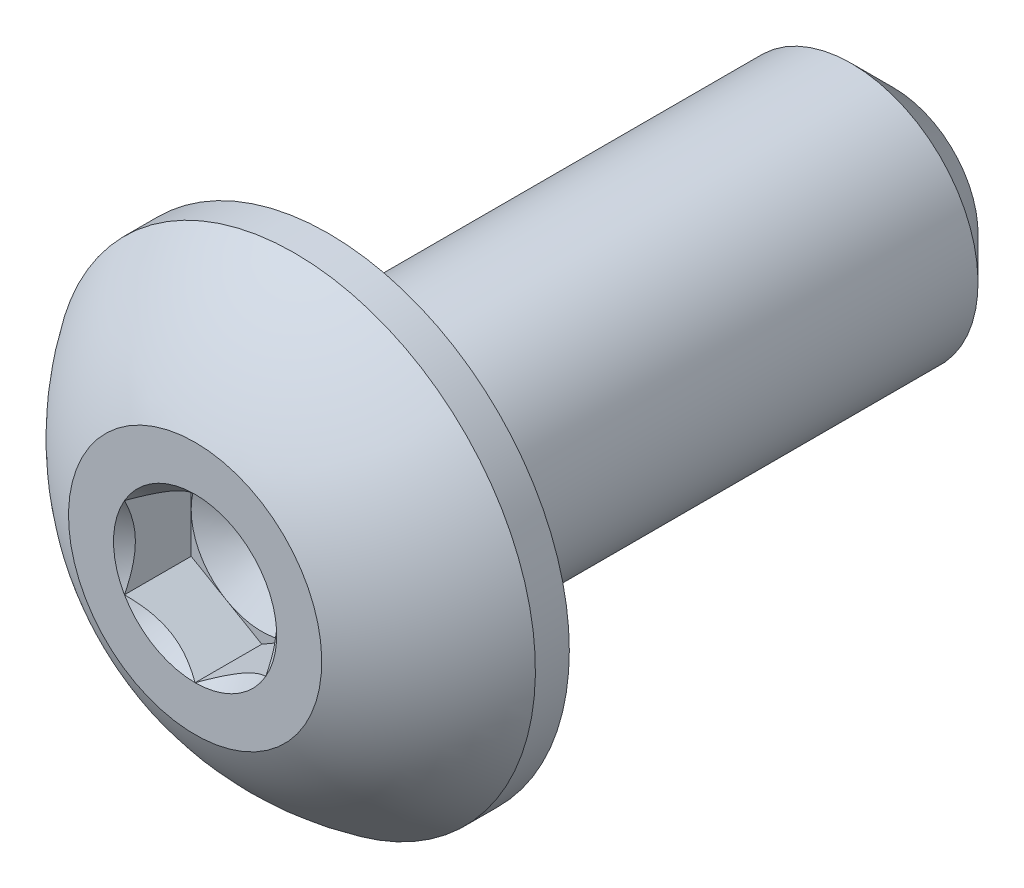
from build123d import *

# Parameters (mm, degrees)
SKETCH1_W          = 6.35
SKETCH1_H          = 1.4224
CHAMFER1_SIZE      = 0.47625
SKETCH4_R          = 2.7051
EXTRUDE1_DEPTH     = 1.4986
CUT_EXTRUDE1_DEPTH = 0.7493
SKETCH7_R          = 0.916543552
CUT_EXTRUDE4_DEPTH = 0.7493
CUT_EXTRUDE4_TAPER = 45
SKETCH8_R          = 0.79375
CUT_EXTRUDE5_DEPTH = 0.249766667
CUT_EXTRUDE5_TAPER = 60


with BuildPart() as part:
    # Sketch1 → Revolve1 (revolve)
    with BuildSketch(Plane(origin=(0, 0, 0), x_dir=(0, 0, -1), z_dir=(1, 0, 0))):
        with Locations((3.175, 0.7112)):
            Rectangle(SKETCH1_W, SKETCH1_H)
    revolve(axis=Axis((0, 0, 0), (0, 0, 1)))

    # Chamfer1
    chamfer1_edges = [part.edges().sort_by_distance(p)[0] for p in [
        (0, -1.4224, -6.35),
    ]]
    chamfer(chamfer1_edges, length=CHAMFER1_SIZE)

    # Sketch4 → Extrude1 (add)
    with BuildSketch(Plane.XY):
        Circle(SKETCH4_R)
    extrude(amount=EXTRUDE1_DEPTH)

    # Sketch9 → Cut-Revolve3 (revolve, cut)
    with BuildSketch(Plane(origin=(0, 0, 0), x_dir=(0, 0, -1), z_dir=(1, 0, 0))):
        with BuildLine():
            Line((0, 2.7051), (-0.381, 2.7051))
            ThreePointArc((-0.381, 2.7051), (-1.025093234, 2.138064897), (-1.4986, 1.4224))
            Line((-1.4986, 1.4224), (-1.8796, 1.4224))
            Line((-1.8796, 1.4224), (-1.8796, 3.0861))
            Line((-1.8796, 3.0861), (0, 3.0861))
            Line((0, 3.0861), (0, 2.7051))
        make_face()
    revolve(axis=Axis((0, 0, 0), (0, 0, 1)), mode=Mode.SUBTRACT)

    # Sketch6 → Cut-Extrude1 (cut)
    with BuildSketch(Plane.XY.offset(1.4986)):
        Polygon((0, -0.916543552), (0.79375, -0.458271776), (0.79375, 0.458271776), (0, 0.916543552), (-0.79375, 0.458271776), (-0.79375, -0.458271776), align=None)
    extrude(amount=-CUT_EXTRUDE1_DEPTH, mode=Mode.SUBTRACT)

    # Sketch7 → Cut-Extrude4 (cut)
    with BuildSketch(Plane.XY.offset(1.4986)):
        Circle(SKETCH7_R)
    extrude(amount=-CUT_EXTRUDE4_DEPTH, taper=CUT_EXTRUDE4_TAPER, mode=Mode.SUBTRACT)

    # Sketch8 → Cut-Extrude5 (cut)
    with BuildSketch(Plane.XY.offset(0.7493)):
        Circle(SKETCH8_R)
    extrude(amount=-CUT_EXTRUDE5_DEPTH, taper=CUT_EXTRUDE5_TAPER, mode=Mode.SUBTRACT)


solid = part.part
